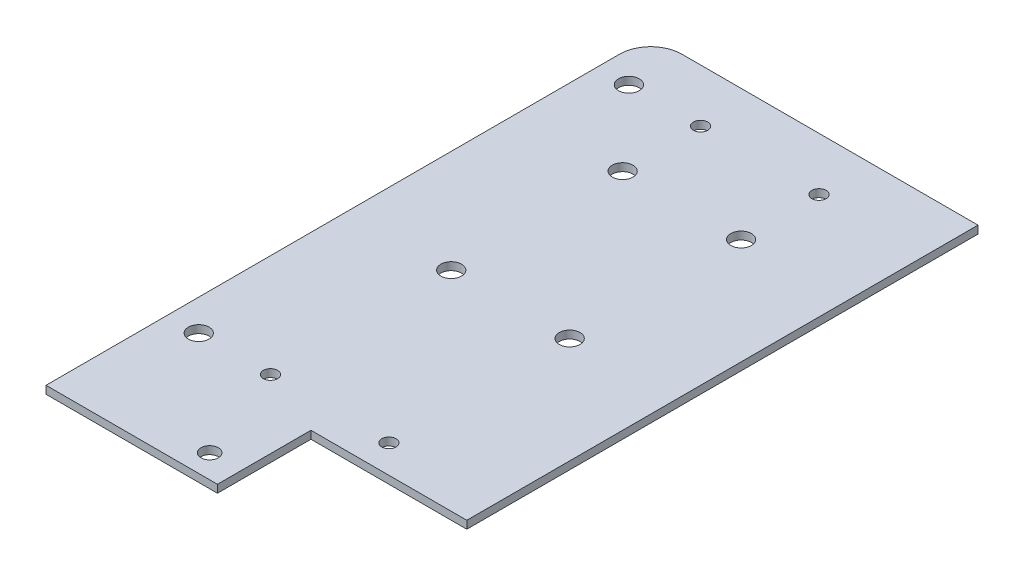
from build123d import *

# Parameters (mm, degrees)
SKETCH1_R           = 1.66
SKETCH1_R_2         = 1.15
SKETCH1_R_3         = 1.4
BOSS_EXTRUDE1_DEPTH = 1.25
FILLET1_R           = 5


with BuildPart() as part:
    # Sketch1 → Boss-Extrude1 (new body)
    with BuildSketch(Plane(origin=(0, 0, 0), x_dir=(1, 0, 0), z_dir=(0, 1, 0))):
        Polygon((-14.713467049, 74.209885387), (-14.713467049, -22.790114613), (12.786532951, -22.790114613), (12.786532951, -7.790114613), (37.786532951, -7.790114613), (37.786532951, 74.209885387), align=None)
        with Locations(Location((-9.713467049, 65.709885387, 0), (0, 0, 270))):  # turned: the seam where the file's is
            Circle(SKETCH1_R, mode=Mode.SUBTRACT)
        with Locations(Location((1.786532951, 65.709885387, 0), (0, 0, 270))):  # turned: the seam where the file's is
            Circle(SKETCH1_R_2, mode=Mode.SUBTRACT)
        with Locations(Location((20.786532951, 65.709885387, 0), (0, 0, 270))):  # turned: the seam where the file's is
            Circle(SKETCH1_R_2, mode=Mode.SUBTRACT)
        with Locations(Location((1.786532951, 53.209885387, 0), (0, 0, 270))):  # turned: the seam where the file's is
            Circle(SKETCH1_R, mode=Mode.SUBTRACT)
        with Locations(Location((1.786532951, 25.709885387, 0), (0, 0, 270))):  # turned: the seam where the file's is
            Circle(SKETCH1_R, mode=Mode.SUBTRACT)
        with Locations(Location((20.786532951, 53.209885387, 0), (0, 0, 270))):  # turned: the seam where the file's is
            Circle(SKETCH1_R, mode=Mode.SUBTRACT)
        with Locations(Location((20.786532951, 25.709885387, 0), (0, 0, 270))):  # turned: the seam where the file's is
            Circle(SKETCH1_R, mode=Mode.SUBTRACT)
        with Locations(Location((1.786532951, -3.290114613, 0), (0, 0, 270))):  # turned: the seam where the file's is
            Circle(SKETCH1_R_2, mode=Mode.SUBTRACT)
        with Locations(Location((20.786532951, -3.290114613, 0), (0, 0, 270))):  # turned: the seam where the file's is
            Circle(SKETCH1_R_2, mode=Mode.SUBTRACT)
        with Locations(Location((-9.713467049, -3.290114613, 0), (0, 0, 270))):  # turned: the seam where the file's is
            Circle(SKETCH1_R, mode=Mode.SUBTRACT)
        with Locations(Location((7.786532951, -19.040114613, 0), (0, 0, 270))):  # turned: the seam where the file's is
            Circle(SKETCH1_R_3, mode=Mode.SUBTRACT)
    extrude(amount=BOSS_EXTRUDE1_DEPTH)

    # Fillet1
    fillet1_edges = [part.edges().sort_by_distance(p)[0] for p in [
        (-14.713467049, 0.625, -74.209885387),
    ]]
    fillet(fillet1_edges, radius=FILLET1_R)


solid = part.part
